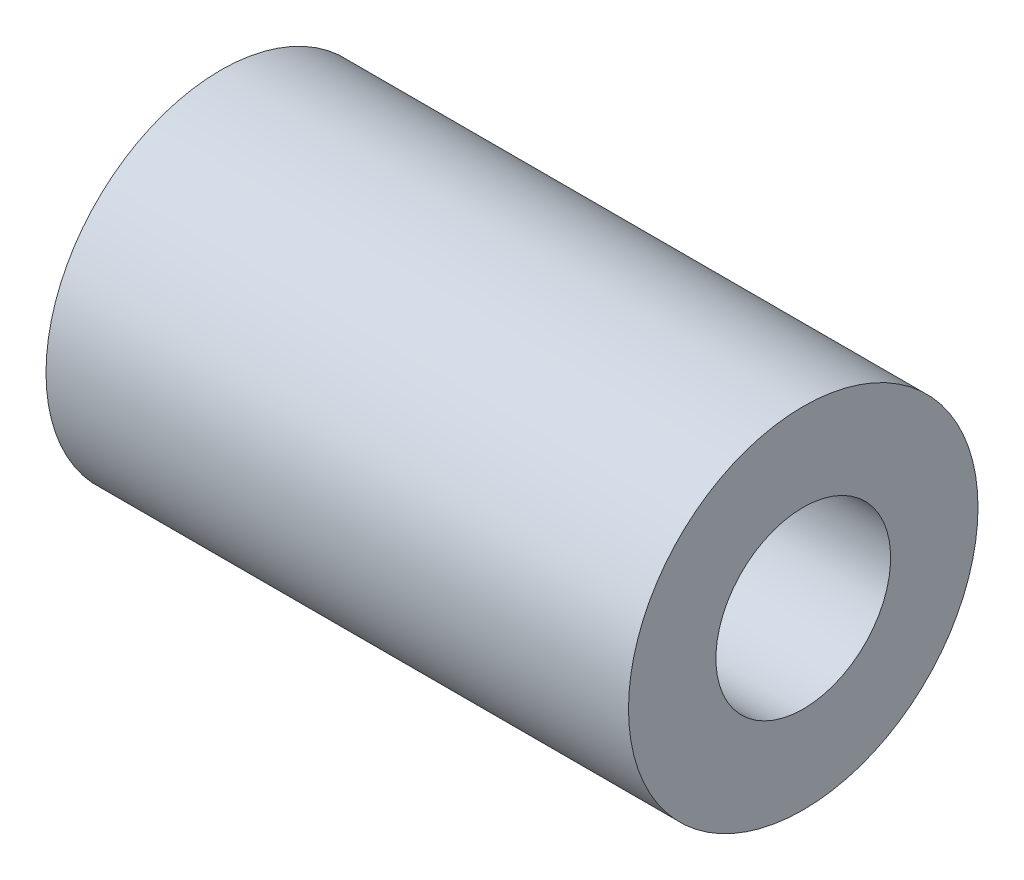
from build123d import *


with BuildPart() as part:
    # Esquisse1 → Révolution1 (revolve)
    with BuildSketch(Plane.XY):
        Polygon((0, 0), (0, 6), (20, 6), (20, 3), (10, 3), (10, 0), align=None)
    revolve(axis=Axis((10, 0, 0), (-1, 0, 0)))


solid = part.part
